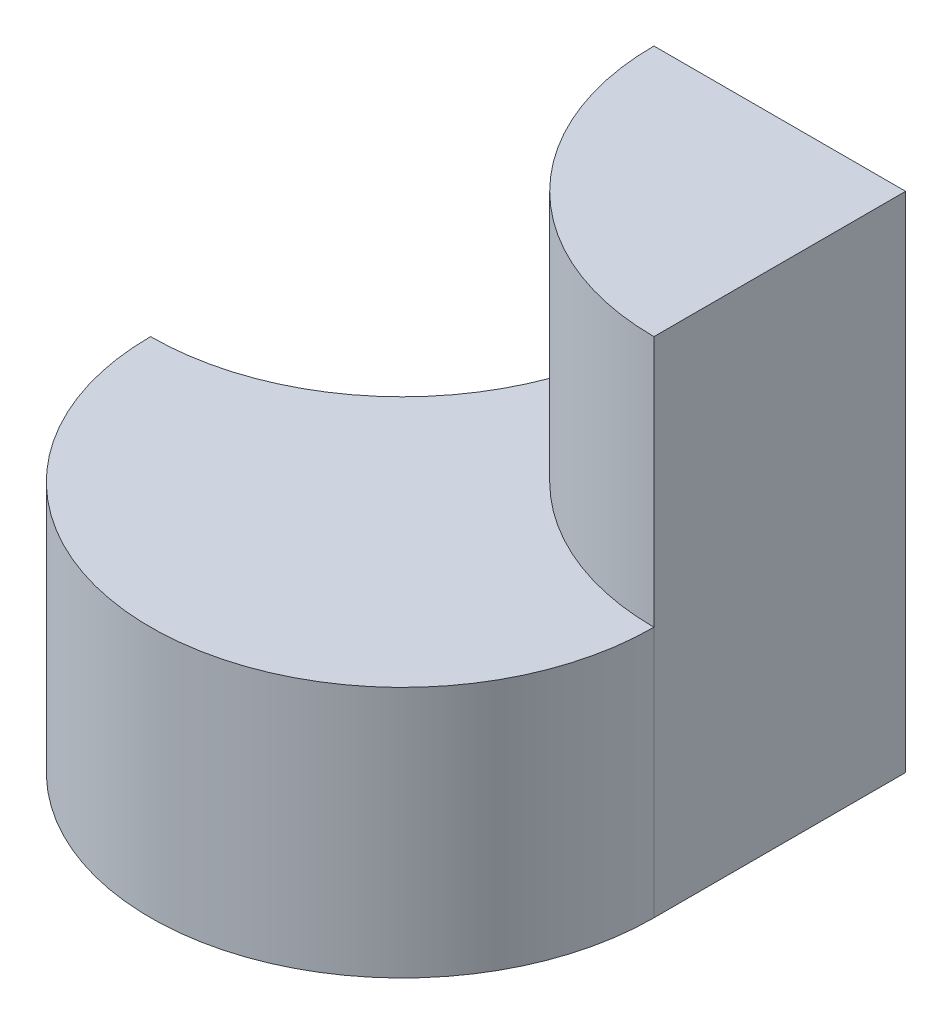
from build123d import *

# Parameters (mm, degrees)
BOSS_EXTRUDE1_DEPTH = 40
CUT_EXTRUDE1_DEPTH  = 40
SKETCH3_W           = 20
SKETCH3_H           = 20
CUT_EXTRUDE2_DEPTH  = 20
BOSS_EXTRUDE4_DEPTH = 20
CUT_EXTRUDE3_DEPTH  = 20


with BuildPart() as part:
    # Sketch1 → Boss-Extrude1 (new body)
    with BuildSketch(Plane.XY):
        Polygon((0, 0), (0, 40), (20, 40), (20, 20), (40, 20), (40, 0), align=None)
    extrude(amount=BOSS_EXTRUDE1_DEPTH)

    # Sketch2 → Cut-Extrude1 (cut)
    with BuildSketch(Plane(origin=(0, 0, 0), x_dir=(-1, 0, 0), z_dir=(0, -1, 0))):
        with BuildLine():
            Line((0, -40), (0, -20))
            ThreePointArc((0, -20), (-5.857864376, -34.142135624), (-20, -40))
            Line((-20, -40), (0, -40))
        make_face()
        with BuildLine():
            Line((-40, -40), (-20, -40))
            ThreePointArc((-20, -40), (-34.142135624, -34.142135624), (-40, -20))
            Line((-40, -20), (-40, -40))
        make_face()
    extrude(amount=-CUT_EXTRUDE1_DEPTH, mode=Mode.SUBTRACT)

    # Sketch3 → Cut-Extrude2 (cut)
    with BuildSketch(Plane(origin=(0, 20, 0), x_dir=(1, 0, 0), z_dir=(0, 1, 0))):
        with Locations((10, -10)):
            Rectangle(SKETCH3_W, SKETCH3_H)
    extrude(amount=CUT_EXTRUDE2_DEPTH, mode=Mode.SUBTRACT)

    # Sketch4 → Boss-Extrude4 (add)
    with BuildSketch(Plane(origin=(0, 20, 0), x_dir=(1, 0, 0), z_dir=(0, 1, 0))):
        with BuildLine():
            Line((20, 0), (40, 0))
            Line((40, 0), (40, -20))
            ThreePointArc((40, -20), (25.857864376, -14.142135624), (20, 0))
        make_face()
    extrude(amount=BOSS_EXTRUDE4_DEPTH)

    # Sketch5 → Cut-Extrude3 (cut)
    with BuildSketch(Plane(origin=(0, 40, 0), x_dir=(1, 0, 0), z_dir=(0, 1, 0))):
        with BuildLine():
            ThreePointArc((0, -20), (5.857864376, -34.142135624), (20, -40))
            Line((20, -40), (20, -20))
            Line((20, -20), (0, -20))
        make_face()
    extrude(amount=-CUT_EXTRUDE3_DEPTH, mode=Mode.SUBTRACT)

    # Sketch6 → Cut-Revolve1 (revolve, cut)
    with BuildSketch(Plane.ZY):
        Polygon((0, 0), (20, 20), (0, 20), align=None)
    revolve(axis=Axis((0, 0, 0), (0, 1, 0)), mode=Mode.SUBTRACT)


solid = part.part
